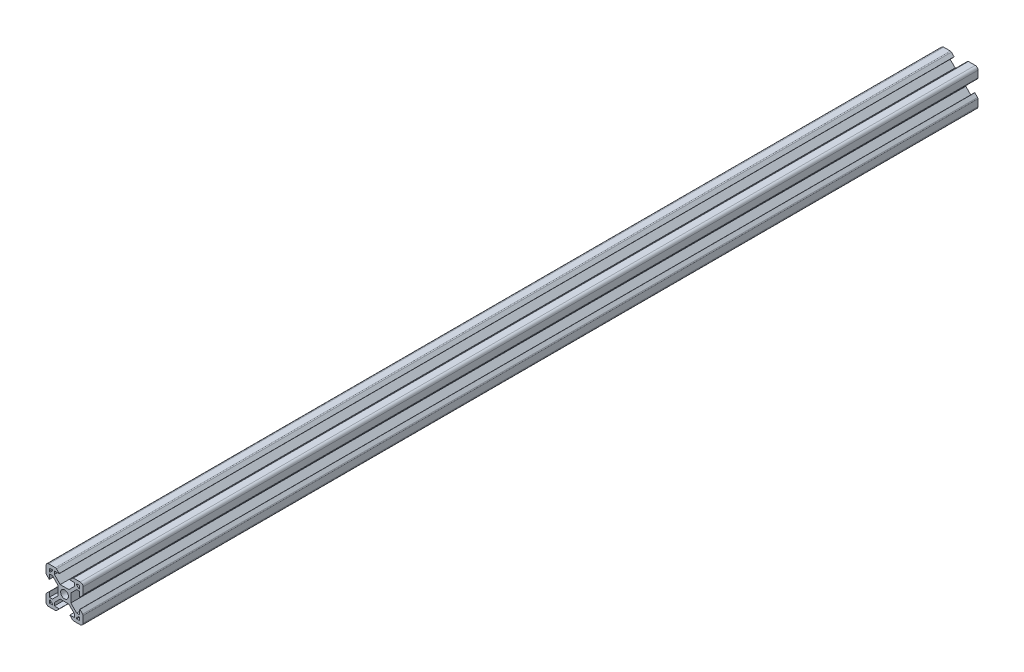
from build123d import *

# Parameters (mm, degrees)
SKETCH6_R           = 2.1
BOSS_EXTRUDE1_DEPTH = 483


with BuildPart() as part:
    # Sketch6 → Boss-Extrude1 (new body)
    with BuildSketch(Plane.XY):
        with BuildLine():
            Line((-3.4, -2.339339828), (-3.4, 2.339339828))
            Line((-3.4, 2.339339828), (-6.560660172, 5.5))
            Line((-6.560660172, 5.5), (-8.2, 5.5))
            Line((-8.2, 5.5), (-8.2, 2.89))
            Line((-8.2, 2.89), (-8.31, 2.89))
            Line((-8.31, 2.89), (-9.768614357, 4.348614357))
            ThreePointArc((-9.768614357, 4.348614357), (-9.939864831, 4.604908803), (-10, 4.907228714))
            Line((-10, 4.907228714), (-10, 8.5))
            ThreePointArc((-10, 8.5), (-9.560660172, 9.560660172), (-8.5, 10))
            Line((-8.5, 10), (-4.907228714, 10))
            ThreePointArc((-4.907228714, 10), (-4.604908803, 9.939864831), (-4.348614357, 9.768614357))
            Line((-4.348614357, 9.768614357), (-2.89, 8.31))
            Line((-2.89, 8.31), (-2.89, 8.2))
            Line((-2.89, 8.2), (-5.5, 8.2))
            Line((-5.5, 8.2), (-5.5, 6.560660172))
            Line((-5.5, 6.560660172), (-2.339339828, 3.4))
            Line((-2.339339828, 3.4), (2.339339828, 3.4))
            Line((2.339339828, 3.4), (5.5, 6.560660172))
            Line((5.5, 6.560660172), (5.5, 8.2))
            Line((5.5, 8.2), (2.89, 8.2))
            Line((2.89, 8.2), (2.89, 8.31))
            Line((2.89, 8.31), (4.348614357, 9.768614357))
            ThreePointArc((4.348614357, 9.768614357), (4.604908803, 9.939864831), (4.907228714, 10))
            Line((4.907228714, 10), (8.5, 10))
            ThreePointArc((8.5, 10), (9.560660172, 9.560660172), (10, 8.5))
            Line((10, 8.5), (10, 4.907228714))
            ThreePointArc((10, 4.907228714), (9.939864831, 4.604908803), (9.768614357, 4.348614357))
            Line((9.768614357, 4.348614357), (8.31, 2.89))
            Line((8.31, 2.89), (8.2, 2.89))
            Line((8.2, 2.89), (8.2, 5.5))
            Line((8.2, 5.5), (6.560660172, 5.5))
            Line((6.560660172, 5.5), (3.4, 2.339339828))
            Line((3.4, 2.339339828), (3.4, -2.339339828))
            Line((3.4, -2.339339828), (6.560660172, -5.5))
            Line((6.560660172, -5.5), (8.2, -5.5))
            Line((8.2, -5.5), (8.2, -2.89))
            Line((8.2, -2.89), (8.31, -2.89))
            Line((8.31, -2.89), (9.768614357, -4.348614357))
            ThreePointArc((9.768614357, -4.348614357), (9.939864831, -4.604908803), (10, -4.907228714))
            Line((10, -4.907228714), (10, -8.5))
            ThreePointArc((10, -8.5), (9.560660172, -9.560660172), (8.5, -10))
            Line((8.5, -10), (4.907228714, -10))
            ThreePointArc((4.907228714, -10), (4.604908803, -9.939864831), (4.348614357, -9.768614357))
            Line((4.348614357, -9.768614357), (2.89, -8.31))
            Line((2.89, -8.31), (2.89, -8.2))
            Line((2.89, -8.2), (5.5, -8.2))
            Line((5.5, -8.2), (5.5, -6.560660172))
            Line((5.5, -6.560660172), (2.339339828, -3.4))
            Line((2.339339828, -3.4), (-2.339339828, -3.4))
            Line((-2.339339828, -3.4), (-5.5, -6.560660172))
            Line((-5.5, -6.560660172), (-5.5, -8.2))
            Line((-5.5, -8.2), (-2.89, -8.2))
            Line((-2.89, -8.2), (-2.89, -8.31))
            Line((-2.89, -8.31), (-4.348614357, -9.768614357))
            ThreePointArc((-4.348614357, -9.768614357), (-4.604908803, -9.939864831), (-4.907228714, -10))
            Line((-4.907228714, -10), (-8.5, -10))
            ThreePointArc((-8.5, -10), (-9.560660172, -9.560660172), (-10, -8.5))
            Line((-10, -8.5), (-10, -4.907228714))
            ThreePointArc((-10, -4.907228714), (-9.939864831, -4.604908803), (-9.768614357, -4.348614357))
            Line((-9.768614357, -4.348614357), (-8.31, -2.89))
            Line((-8.31, -2.89), (-8.2, -2.89))
            Line((-8.2, -2.89), (-8.2, -5.5))
            Line((-8.2, -5.5), (-6.560660172, -5.5))
            Line((-6.560660172, -5.5), (-3.4, -2.339339828))
        make_face()
        Circle(SKETCH6_R, mode=Mode.SUBTRACT)
        Polygon((-7.66, 6.57), (-6.57, 7.66), (-6.57, 8.2), (-8.2, 8.2), (-8.2, 6.57), align=None, mode=Mode.SUBTRACT)
        Polygon((8.2, 6.57), (7.66, 6.57), (6.57, 7.66), (6.57, 8.2), (8.2, 8.2), align=None, mode=Mode.SUBTRACT)
        Polygon((7.66, -6.57), (6.57, -7.66), (6.57, -8.2), (8.2, -8.2), (8.2, -6.57), align=None, mode=Mode.SUBTRACT)
        Polygon((-8.2, -6.57), (-7.66, -6.57), (-6.57, -7.66), (-6.57, -8.2), (-8.2, -8.2), align=None, mode=Mode.SUBTRACT)
    extrude(amount=-BOSS_EXTRUDE1_DEPTH)


solid = part.part
